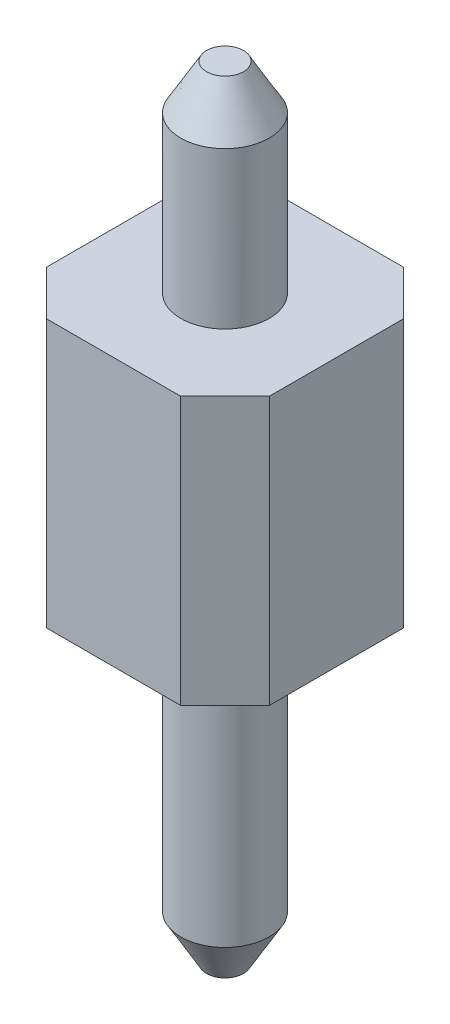
from build123d import *

# Parameters (mm, degrees)
SKETCH1_W           = 2.5
SKETCH1_H           = 2.5
BOSS_EXTRUDE1_DEPTH = 1.5
SKETCH2_R           = 0.4953
BOSS_EXTRUDE2_DEPTH = 2.25
CHAMFER1_SIZE       = 0.5
CHAMFER1_SIZE2      = 0.288675135
CHAMFER2_SIZE       = 0.5
SKETCH4_R           = 0.4953
BOSS_EXTRUDE3_DEPTH = 3.5
CHAMFER3_SIZE       = 0.5
CHAMFER3_SIZE2      = 0.288675135


with BuildPart() as part:
    # Sketch1 → Boss-Extrude1 (new body, symmetric)
    with BuildSketch(Plane(origin=(0, 0, 0), x_dir=(1, 0, 0), z_dir=(0, 1, 0))):
        Rectangle(SKETCH1_W, SKETCH1_H)
    extrude(amount=BOSS_EXTRUDE1_DEPTH, both=True)

    # Sketch2 → Boss-Extrude2 (add)
    with BuildSketch(Plane(origin=(0, 1.5, 0), x_dir=(1, 0, 0), z_dir=(0, 1, 0))):
        Circle(SKETCH2_R)
    extrude(amount=BOSS_EXTRUDE2_DEPTH)

    # Chamfer1
    chamfer1_edges = [part.edges().sort_by_distance(p)[0] for p in [
        (-0.4953, 3.75, 0),
    ]]
    chamfer1_side = [part.faces().sort_by_distance(p)[0] for p in [
        (-0.4953, 2.625, 0),
    ]]
    chamfer(chamfer1_edges, length=CHAMFER1_SIZE, length2=CHAMFER1_SIZE2, reference=chamfer1_side[0])

    # Chamfer2
    chamfer2_edges = [part.edges().sort_by_distance(p)[0] for p in [
        (-1.25, 0, 1.25),
        (-1.25, 0, -1.25),
        (1.25, 0, -1.25),
        (1.25, 0, 1.25),
    ]]
    chamfer(chamfer2_edges, length=CHAMFER2_SIZE)

    # Sketch4 → Boss-Extrude3 (add)
    with BuildSketch(Plane.XZ.offset(1.5)):
        Circle(SKETCH4_R)
    extrude(amount=BOSS_EXTRUDE3_DEPTH)

    # Chamfer3
    chamfer3_edges = [part.edges().sort_by_distance(p)[0] for p in [
        (-0.4953, -5, 0),
    ]]
    chamfer3_side = [part.faces().sort_by_distance(p)[0] for p in [
        (-0.4953, -3.25, 0),
    ]]
    chamfer(chamfer3_edges, length=CHAMFER3_SIZE, length2=CHAMFER3_SIZE2, reference=chamfer3_side[0])


solid = part.part
